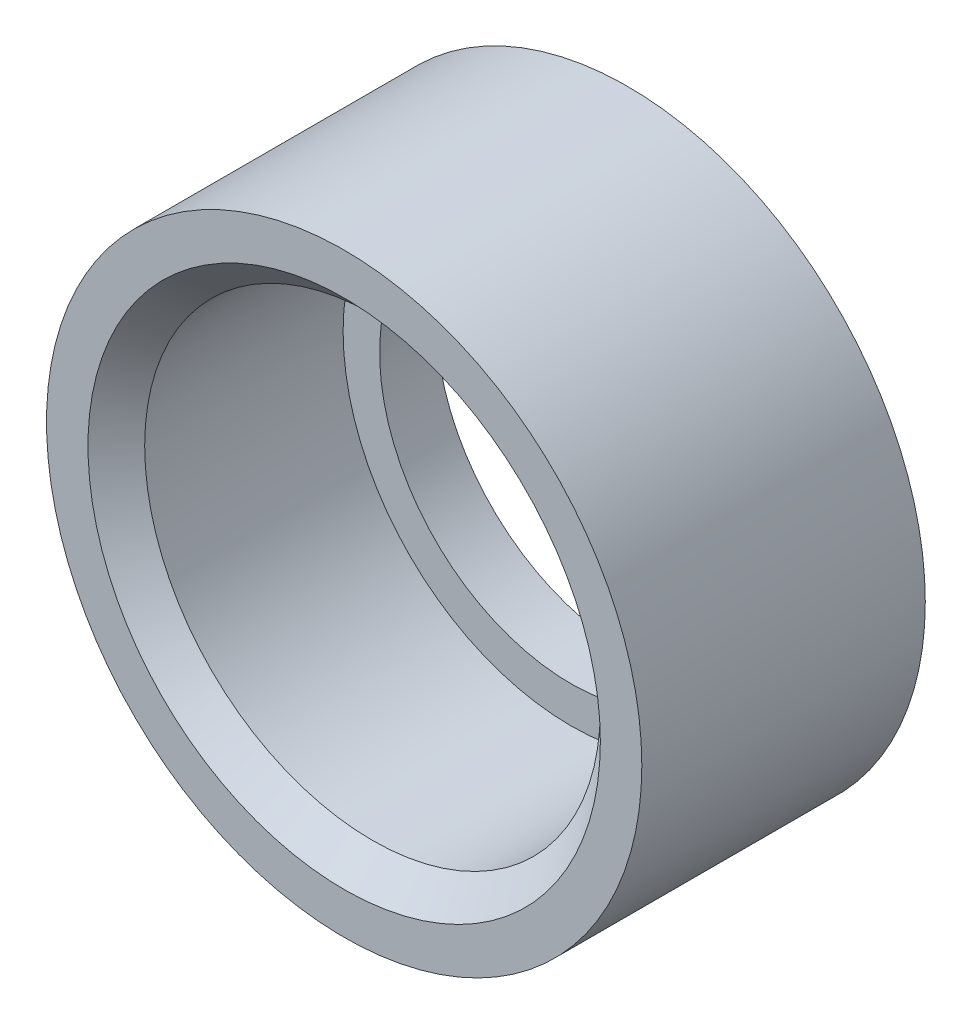
from build123d import *

# Parameters (mm, degrees)
SKETCH1_R           = 10.5
SKETCH1_R_2         = 8.0375
BOSS_EXTRUDE1_DEPTH = 5
BOSS_EXTRUDE2_START = -5
SKETCH1_3_R         = 8.0375
SKETCH1_3_R_2       = 6.75
BOSS_EXTRUDE2_DEPTH = 2
CHAMFER1_SIZE       = 1


with BuildPart() as part:
    # Sketch1 → Boss-Extrude1 (new body, symmetric)
    with BuildSketch(Plane.XY):
        Circle(SKETCH1_R)
        Circle(SKETCH1_R_2, mode=Mode.SUBTRACT)
    extrude(amount=BOSS_EXTRUDE1_DEPTH, both=True)

    # Sketch1_3 → Boss-Extrude2 (add)
    with BuildSketch(Plane.XY.offset(BOSS_EXTRUDE2_START)):
        Circle(SKETCH1_3_R)
        Circle(SKETCH1_3_R_2, mode=Mode.SUBTRACT)
    extrude(amount=BOSS_EXTRUDE2_DEPTH)

    # Chamfer1
    chamfer1_edges = [part.edges().sort_by_distance(p)[0] for p in [
        (-8.0375, 0, 5),
    ]]
    chamfer(chamfer1_edges, length=CHAMFER1_SIZE)


solid = part.part
